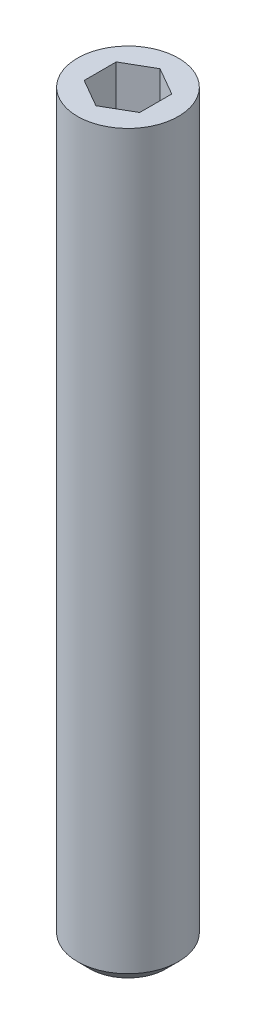
from build123d import *

# Parameters (mm, degrees)
SKETCH1_R           = 2
BOSS_EXTRUDE1_DEPTH = 29.5
CHAMFER1_SIZE       = 0.5
CUT_EXTRUDE1_DEPTH  = 2


with BuildPart() as part:
    # Sketch1 → Boss-Extrude1 (new body)
    with BuildSketch(Plane(origin=(0, 0, 0), x_dir=(1, 0, 0), z_dir=(0, 1, 0))):
        Circle(SKETCH1_R)
    extrude(amount=BOSS_EXTRUDE1_DEPTH)

    # Chamfer1
    chamfer1_edges = [part.edges().sort_by_distance(p)[0] for p in [
        (-2, 0, 0),
    ]]
    chamfer(chamfer1_edges, length=CHAMFER1_SIZE)

    # Sketch2 → Cut-Extrude1 (cut)
    with BuildSketch(Plane(origin=(0, 29.5, 0), x_dir=(1, 0, 0), z_dir=(0, 1, 0))):
        Polygon((1.1, 0.635085296), (0, 1.270170592), (-1.1, 0.635085296), (-1.1, -0.635085296), (0, -1.270170592), (1.1, -0.635085296), align=None)
    extrude(amount=-CUT_EXTRUDE1_DEPTH, mode=Mode.SUBTRACT)


solid = part.part
